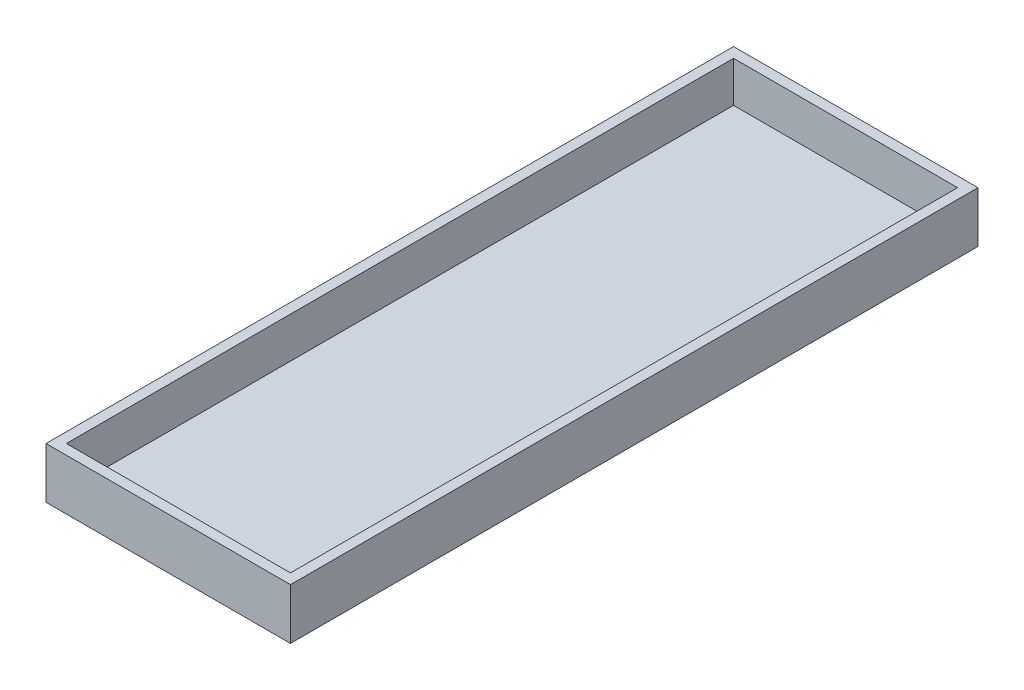
from build123d import *

# Parameters (mm, degrees)
SKETCH3_W           = 96
SKETCH3_H           = 20
BOSS_EXTRUDE1_DEPTH = 270
SHELL1_T            = -4


with BuildPart() as part:
    # Sketch3 → Boss-Extrude1 (new body)
    with BuildSketch(Plane.XY):
        with Locations((48, 10)):
            Rectangle(SKETCH3_W, SKETCH3_H)
    extrude(amount=-BOSS_EXTRUDE1_DEPTH)

    # Shell1
    shell1_openings = [part.faces().sort_by_distance(p)[0] for p in [
        (48, 20, -135),
    ]]
    offset(amount=SHELL1_T, openings=shell1_openings, kind=Kind.INTERSECTION)


solid = part.part
